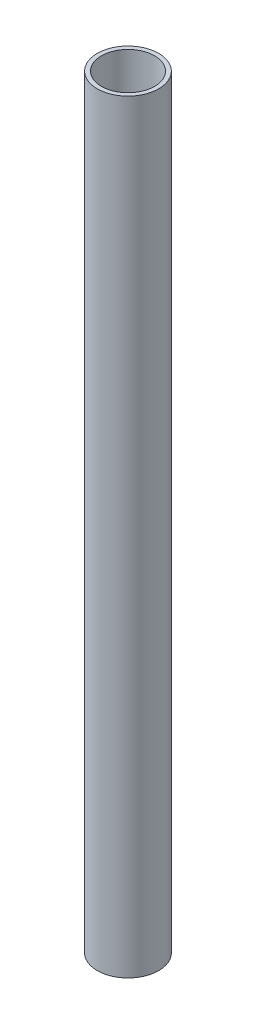
from build123d import *

# Parameters (mm, degrees)
SKETCH1_R           = 18.5
SKETCH1_R_2         = 16
BOSS_EXTRUDE1_DEPTH = 460


with BuildPart() as part:
    # Sketch1 → Boss-Extrude1 (new body)
    with BuildSketch(Plane(origin=(0, 0, 0), x_dir=(1, 0, 0), z_dir=(0, 1, 0))):
        Circle(SKETCH1_R)
        Circle(SKETCH1_R_2, mode=Mode.SUBTRACT)
    extrude(amount=BOSS_EXTRUDE1_DEPTH)


solid = part.part
